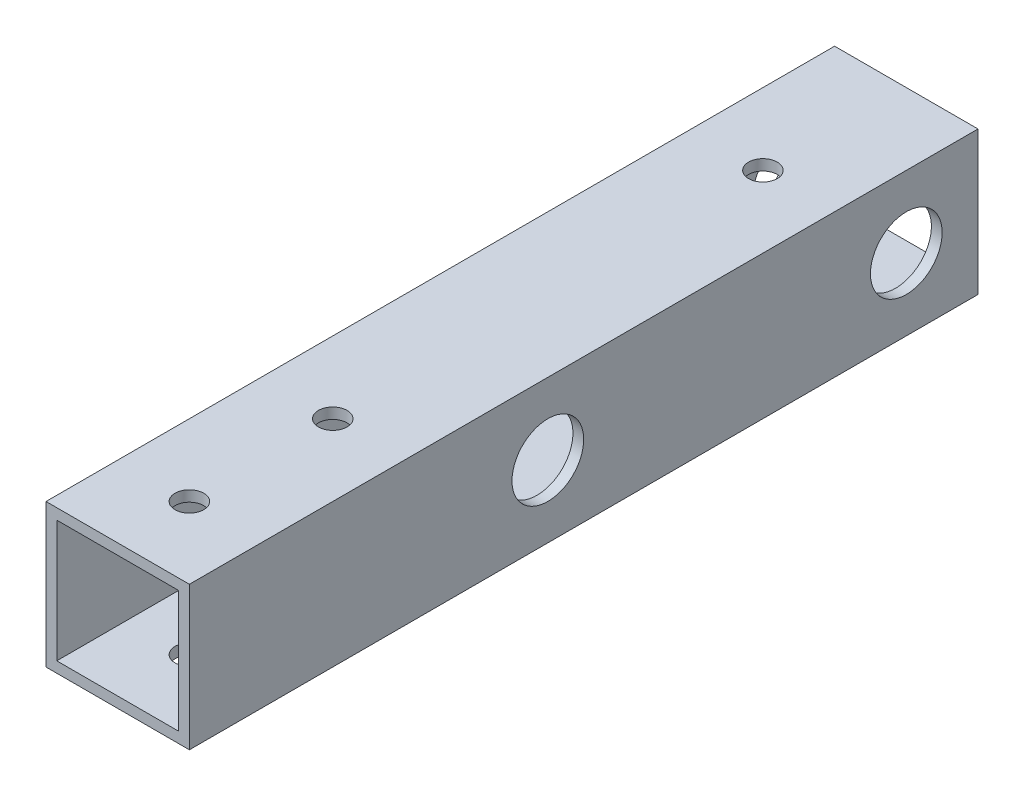
from build123d import *

# Parameters (mm, degrees)
SKETCH_1_W          = 20
SKETCH_1_H          = 20
SKETCH_1_W_2        = 17
SKETCH_1_H_2        = 17
EXTRUDE_1_DEPTH     = 110
SKETCH_2_R          = 2.7
CUT_EXTRUDE_1_DEPTH = 25
SKETCH_3_R          = 2
CUT_EXTRUDE_2_DEPTH = 20
SKETCH_5_R          = 5
CUT_EXTRUDE_4_DEPTH = 10
CUT_EXTRUDE_START   = -10
SKETCH_6_R          = 5
CUT_EXTRUDE_5_DEPTH = 10


with BuildPart() as part:
    # ｽｹｯﾁ1 → ﾎﾞｽ - 押し出し1 (new body)
    with BuildSketch(Plane.XY):
        Rectangle(SKETCH_1_W, SKETCH_1_H)
        Rectangle(SKETCH_1_W_2, SKETCH_1_H_2, mode=Mode.SUBTRACT)
    extrude(amount=EXTRUDE_1_DEPTH)

    # ｽｹｯﾁ2 → ｶｯﾄ - 押し出し1 (cut)
    with BuildSketch(Plane(origin=(10, 0, 0), x_dir=(0, 0, -1), z_dir=(1, 0, 0))):
        with Locations((-60, 0)):
            Circle(SKETCH_2_R)
        with Locations((-10, 0)):
            Circle(SKETCH_2_R)
    extrude(amount=-CUT_EXTRUDE_1_DEPTH, mode=Mode.SUBTRACT)

    # ｽｹｯﾁ3 → ｶｯﾄ - 押し出し2 (cut)
    with BuildSketch(Plane(origin=(0, 10, 0), x_dir=(1, 0, 0), z_dir=(0, 1, 0))):
        with Locations((0, -100)):
            Circle(SKETCH_3_R)
        with Locations((0, -80)):
            Circle(SKETCH_3_R)
        with Locations((0, -20)):
            Circle(SKETCH_3_R)
    extrude(amount=-CUT_EXTRUDE_2_DEPTH, mode=Mode.SUBTRACT)

    # ｽｹｯﾁ5 → ｶｯﾄ - 押し出し4 (cut)
    with BuildSketch(Plane(origin=(0, -10, 0), x_dir=(-1, 0, 0), z_dir=(0, -1, 0))):
        with Locations((0, -20)):
            Circle(SKETCH_5_R)
    extrude(amount=-CUT_EXTRUDE_4_DEPTH, mode=Mode.SUBTRACT)

    # ｽｹｯﾁ6 → ｶｯﾄ - 押し出し5 (cut)
    with BuildSketch(Plane.ZY.offset(10).offset(CUT_EXTRUDE_START)):
        with Locations((10, 0)):
            Circle(SKETCH_6_R)
        with Locations((60, 0)):
            Circle(SKETCH_6_R)
    extrude(amount=-CUT_EXTRUDE_5_DEPTH, mode=Mode.SUBTRACT)


solid = part.part
